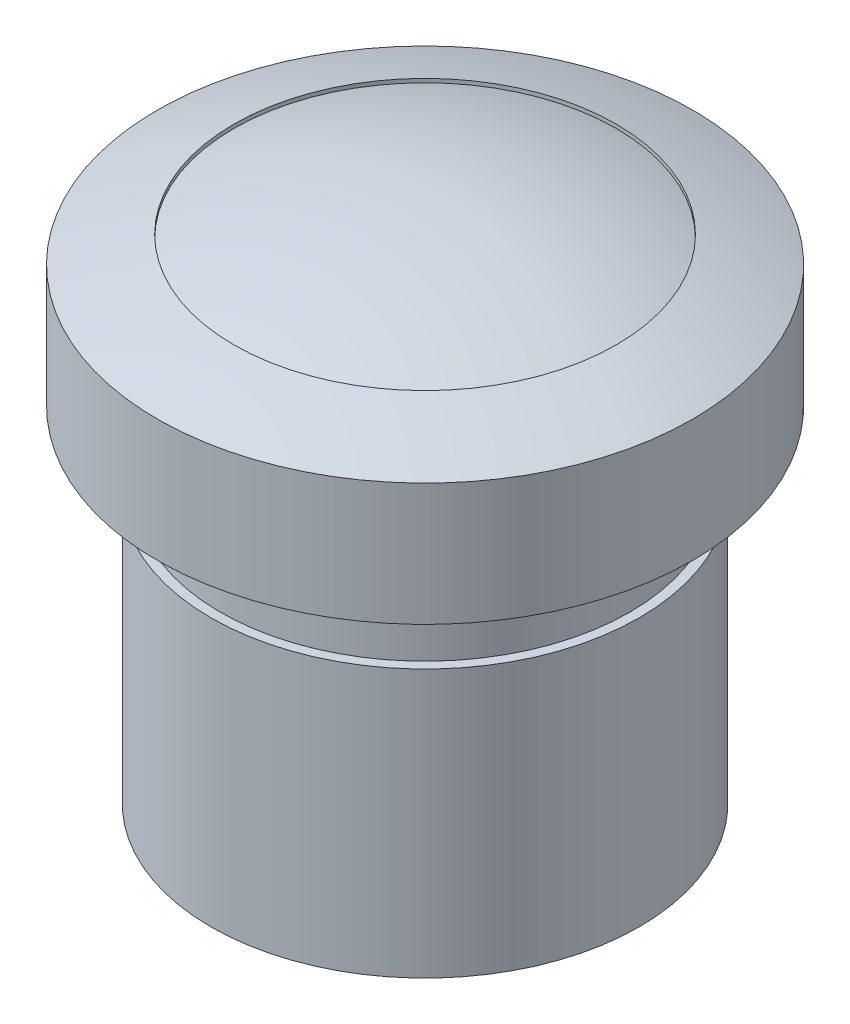
from build123d import *

# Parameters (mm, degrees)
SKETCH1_R           = 5.6
BOSS_EXTRUDE1_DEPTH = 9
SKETCH4_R           = 5.6
SKETCH4_R_2         = 5.35
CUT_EXTRUDE1_DEPTH  = 2
SKETCH5_R           = 5.4
CUT_EXTRUDE3_DEPTH  = 6
BOSS_EXTRUDE2_DEPTH = 6
SKETCH7_W           = 4.5
SKETCH7_H           = 4.5
CUT_EXTRUDE4_DEPTH  = 0.8
SKETCH8_R           = 1.75
CUT_EXTRUDE5_DEPTH  = 1


with BuildPart() as part:
    # Sketch1 → Boss-Extrude1 (new body)
    with BuildSketch(Plane(origin=(0, 0, 0), x_dir=(1, 0, 0), z_dir=(0, 1, 0))):
        Circle(SKETCH1_R)
    extrude(amount=BOSS_EXTRUDE1_DEPTH)

    # Sketch2 → Revolve1 (revolve)
    with BuildSketch(Plane.XY):
        with BuildLine():
            Line((0, 9), (0, 13.7))
            ThreePointArc((0, 13.7), (-2.541861151, 13.468387517), (-5, 12.78117878))
            Line((-5, 12.78117878), (-5, 12.88117878))
            ThreePointArc((-5, 12.88117878), (-6.008472362, 12.565464979), (-7, 12.2))
            Line((-7, 12.2), (-7, 9))
            Line((-7, 9), (0, 9))
        make_face()
    revolve(axis=Axis((0, 9, 0), (0, 1, 0)))

    # Sketch4 → Cut-Extrude1 (cut)
    with BuildSketch(Plane.XZ.offset(-9)):
        Circle(SKETCH4_R)
        Circle(SKETCH4_R_2, mode=Mode.SUBTRACT)
    extrude(amount=CUT_EXTRUDE1_DEPTH, mode=Mode.SUBTRACT)

    # Sketch5 → Cut-Extrude3 (cut)
    with BuildSketch(Plane.XZ):
        Circle(SKETCH5_R)
    extrude(amount=-CUT_EXTRUDE3_DEPTH, mode=Mode.SUBTRACT)

    # Sketch6 → Boss-Extrude2 (add)
    with BuildSketch(Plane.XZ):
        with BuildLine():
            Line((3.291184257, -4.28113375), (1.660050506, -2.65))
            Line((1.660050506, -2.65), (-1.660050506, -2.65))
            Line((-1.660050506, -2.65), (-3.291184257, -4.28113375))
            ThreePointArc((-3.291184257, -4.28113375), (-3.818376618, -3.818376618), (-4.28113375, -3.291184257))
            Line((-4.28113375, -3.291184257), (-2.65, -1.660050506))
            Line((-2.65, -1.660050506), (-2.65, 1.660050506))
            Line((-2.65, 1.660050506), (-4.28113375, 3.291184257))
            ThreePointArc((-4.28113375, 3.291184257), (-3.818376618, 3.818376618), (-3.291184257, 4.28113375))
            Line((-3.291184257, 4.28113375), (-1.660050506, 2.65))
            Line((-1.660050506, 2.65), (1.660050506, 2.65))
            Line((1.660050506, 2.65), (3.291184257, 4.28113375))
            ThreePointArc((3.291184257, 4.28113375), (3.818376618, 3.818376618), (4.28113375, 3.291184257))
            Line((4.28113375, 3.291184257), (2.65, 1.660050506))
            Line((2.65, 1.660050506), (2.65, -1.660050506))
            Line((2.65, -1.660050506), (4.28113375, -3.291184257))
            ThreePointArc((4.28113375, -3.291184257), (3.818376618, -3.818376618), (3.291184257, -4.28113375))
        make_face()
    extrude(amount=-BOSS_EXTRUDE2_DEPTH)

    # Sketch7 → Cut-Extrude4 (cut)
    with BuildSketch(Plane.XZ):
        Rectangle(SKETCH7_W, SKETCH7_H)
    extrude(amount=-CUT_EXTRUDE4_DEPTH, mode=Mode.SUBTRACT)

    # Sketch8 → Cut-Extrude5 (cut)
    with BuildSketch(Plane.XZ.offset(-0.8)):
        Circle(SKETCH8_R)
    extrude(amount=-CUT_EXTRUDE5_DEPTH, mode=Mode.SUBTRACT)

    # Sketch9 → Revolve2 (revolve)
    with BuildSketch(Plane.XY):
        with BuildLine():
            Line((0, 0.8), (0, 1.8))
            Line((0, 1.8), (-1.75, 1.8))
            ThreePointArc((-1.75, 1.8), (-1.007782219, 1.067631118), (0, 0.8))
        make_face()
    revolve(axis=Axis((0, 0.8, 0), (0, 1, 0)))


solid = part.part
